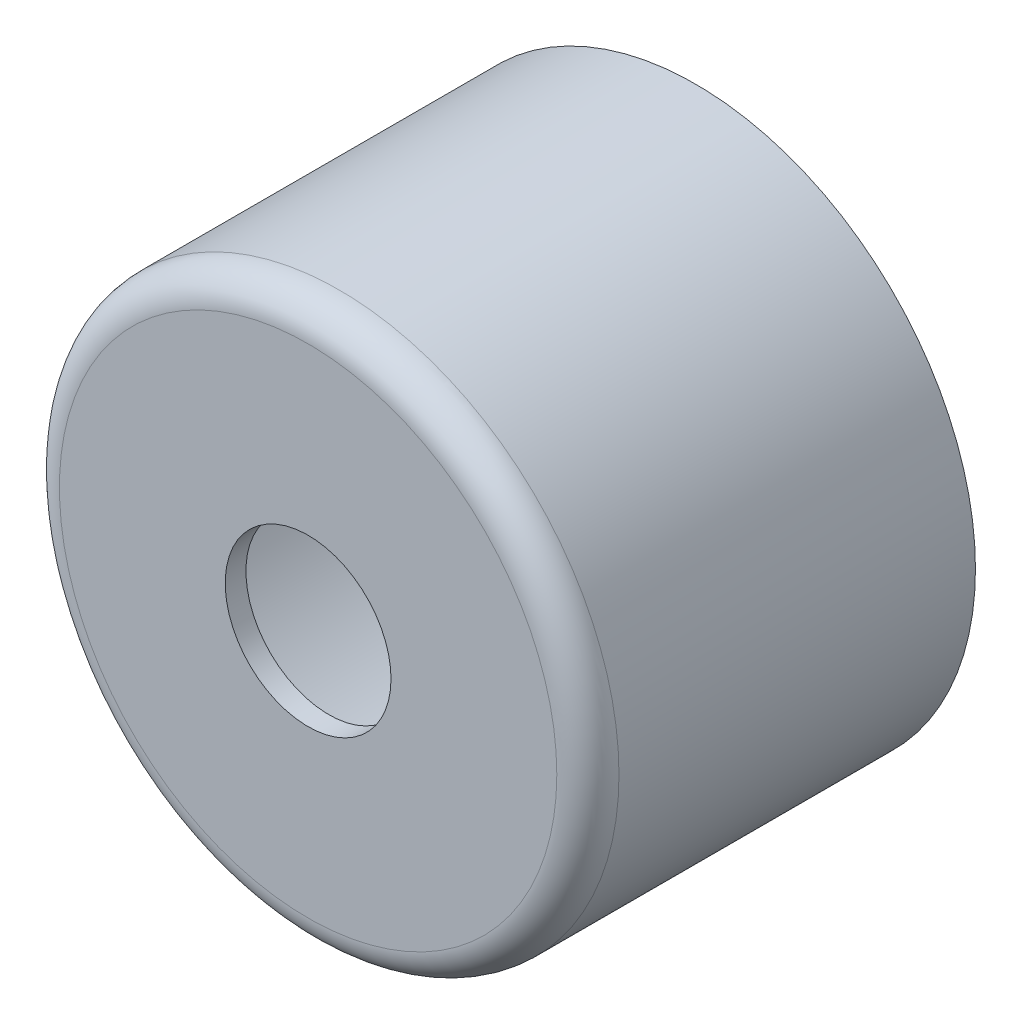
from build123d import *

# Parameters (mm, degrees)
ESQUISSE1_R             = 13.5
EXTRUSION1_DEPTH        = 18.7
CONG_1_R                = 1.5
COQUE1_T                = -1
ESQUISSE2_R             = 4
ENL_V_MAT_EXTRU_1_DEPTH = 19.7


with BuildPart() as part:
    # Esquisse1 → Extrusion1 (new body)
    with BuildSketch(Plane.XY):
        Circle(ESQUISSE1_R)
    extrude(amount=EXTRUSION1_DEPTH)

    # Congé1
    cong_1_edges = [part.edges().sort_by_distance(p)[0] for p in [
        (-13.5, 0, 18.7),
    ]]
    fillet(cong_1_edges, radius=CONG_1_R)

    # Coque1
    coque1_openings = [part.faces().sort_by_distance(p)[0] for p in [
        (0, 0, 0),
    ]]
    offset(amount=COQUE1_T, openings=coque1_openings, kind=Kind.INTERSECTION)

    # Esquisse2 → Enlèv. mat.-Extru.1 (cut, through all)
    with BuildSketch(Plane.XY.offset(18.7)):
        Circle(ESQUISSE2_R)
    extrude(amount=-ENL_V_MAT_EXTRU_1_DEPTH, mode=Mode.SUBTRACT)


solid = part.part
